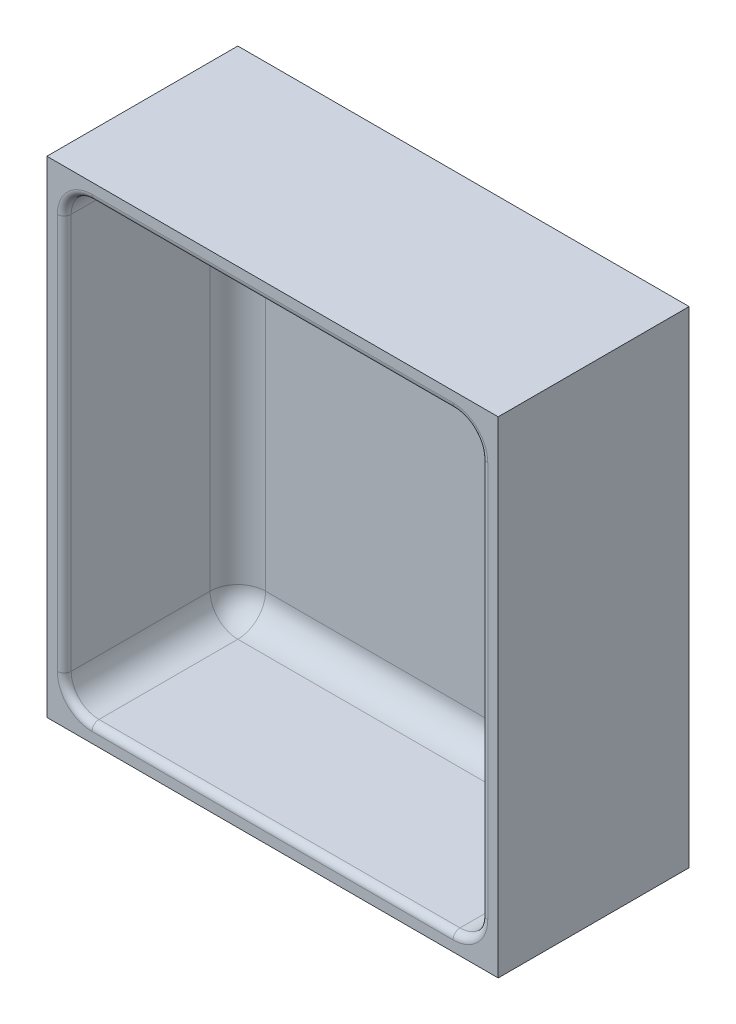
from build123d import *

# Parameters (mm, degrees)
IZIM1_W                     = 130
IZIM1_H                     = 120
Y_KSEKLIK_EKSTR_ZYON1_DEPTH = 5
IZIM1_3_W                   = 140
IZIM1_3_H                   = 130
IZIM1_3_W_2                 = 130
IZIM1_3_H_2                 = 120
Y_KSEKLIK_EKSTR_ZYON2_DEPTH = 55
RADYUS1_R                   = 8
RADYUS2_R                   = 2


with BuildPart() as part:
    # Çizim1 → Yükseklik-Ekstrüzyon1 (new body)
    with BuildSketch(Plane(origin=(0, 0, 0), x_dir=(0, 1, 0), z_dir=(0, 0, 1))):
        with Locations((70, 65)):
            Rectangle(IZIM1_W, IZIM1_H)
    extrude(amount=Y_KSEKLIK_EKSTR_ZYON1_DEPTH)

    # Çizim1<3> → Yükseklik-Ekstrüzyon2 (add)
    with BuildSketch(Plane(origin=(0, 0, 0), x_dir=(0, 1, 0), z_dir=(0, 0, 1))):
        with Locations((70, 65)):
            Rectangle(IZIM1_3_W, IZIM1_3_H)
        with Locations((70, 65)):
            Rectangle(IZIM1_3_W_2, IZIM1_3_H_2, mode=Mode.SUBTRACT)
    extrude(amount=Y_KSEKLIK_EKSTR_ZYON2_DEPTH)

    # Radyus1
    radyus1_edges = [part.edges().sort_by_distance(p)[0] for p in [
        (-5, 135, 30),
        (-125, 135, 30),
        (-125, 5, 30),
        (-5, 5, 30),
        (-5, 70, 5),
        (-65, 135, 5),
        (-125, 70, 5),
        (-65, 5, 5),
    ]]
    fillet(radyus1_edges, radius=RADYUS1_R)

    # Radyus2
    radyus2_edges = [part.edges().sort_by_distance(p)[0] for p in [
        (-122.656854249, 7.343145751, 55),
        (-125, 70, 55),
        (-122.656854249, 132.656854249, 55),
        (-65, 135, 55),
        (-7.343145751, 132.656854249, 55),
        (-5, 70, 55),
        (-7.343145751, 7.343145751, 55),
        (-65, 5, 55),
    ]]
    fillet(radyus2_edges, radius=RADYUS2_R)


solid = part.part
